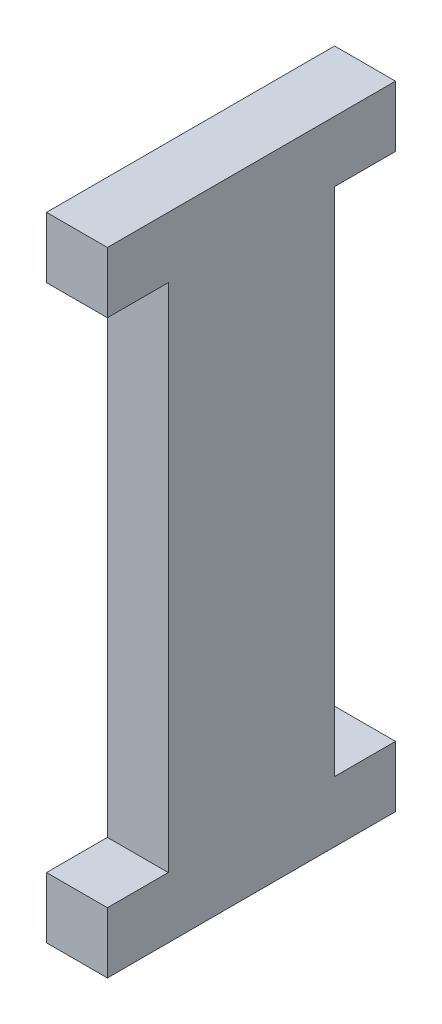
from build123d import *

# Parameters (mm, degrees)
SKETCH1_W           = 3.17
SKETCH1_H           = 3.17
BOSS_EXTRUDE1_DEPTH = 3.17


with BuildPart() as part:
    # Sketch1 → Boss-Extrude1 (new body)
    with BuildSketch(Plane(origin=(0, 0, 0), x_dir=(0, 0, -1), z_dir=(1, 0, 0))):
        with Locations((13.415, 31.355)):
            Rectangle(SKETCH1_W, SKETCH1_H)
        with Locations((1.585, 31.355)):
            Rectangle(SKETCH1_W, SKETCH1_H)
        with Locations((1.585, 1.585)):
            Rectangle(SKETCH1_W, SKETCH1_H)
        with Locations((13.415, 1.585)):
            Rectangle(SKETCH1_W, SKETCH1_H)
        Polygon((11.83, 3.17), (11.83, 29.77), (11.83, 32.94), (3.17, 32.94), (3.17, 29.77), (3.17, 3.17), (3.17, 0), (11.83, 0), align=None)
    extrude(amount=BOSS_EXTRUDE1_DEPTH)


solid = part.part
